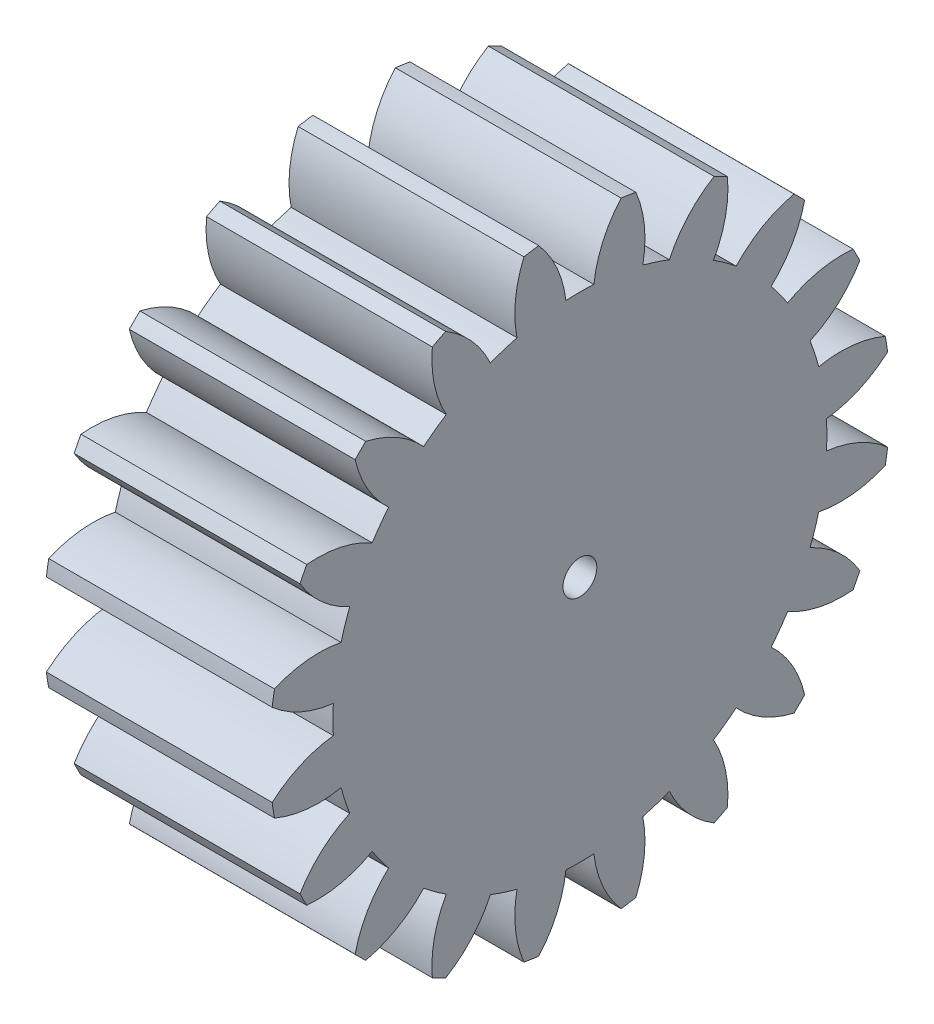
from build123d import *

# Parameters (mm, degrees)
BASPROSKE_W     = 20
BASPROSKE_H     = 27.5
TOOTHCUT_DEPTH  = 44.732139211
TEETHCUTS_COUNT = 20
TEETHCUTS_ANGLE = 342
BORSKE_R        = 1.5
BORE_DEPTH      = 50.0000508


with BuildPart() as part:
    # BasProSke → Base-Revolve (revolve)
    with BuildSketch(Plane(origin=(0, 0, 0), x_dir=(1, 0, 0), z_dir=(0, 1, 0)), mode=Mode.PRIVATE) as base_revolve_sk:
        with Locations((10, 13.75)):
            Rectangle(BASPROSKE_W, BASPROSKE_H)
    revolve(base_revolve_sk.sketch.rotate(Axis((-10, 0, 0), (1, 0, 0)), 180), axis=Axis((-10, 0, 0), (1, 0, 0)))

    # TooCutSke → ToothCut (cut, through all)
    with BuildSketch(Plane(origin=(0, 0, 0), x_dir=(0, 0, -1), z_dir=(1, 0, 0))):
        with BuildLine():
            ThreePointArc((1.237725267, 21.838954008), (0, 21.874), (-1.237725267, 21.838954008))
            ThreePointArc((-1.237725267, 21.838954008), (-2.037783758, 24.744650423), (-3.667234079, 27.280011719))
            ThreePointArc((-3.667234079, 27.280011719), (0, 27.5254), (3.667234079, 27.280011719))
            ThreePointArc((3.667234079, 27.280011719), (2.037783758, 24.744650423), (1.237725267, 21.838954008))
        make_face()
    toothcut = extrude(amount=TOOTHCUT_DEPTH, mode=Mode.SUBTRACT)

    # TeethCuts: ToothCut ×20 about axis
    teethcuts_axis = Axis((-10, 0, 0), (1, 0, 0))
    for i in range(1, TEETHCUTS_COUNT):
        add(toothcut.rotate(teethcuts_axis, i * TEETHCUTS_ANGLE / (TEETHCUTS_COUNT - 1)), mode=Mode.SUBTRACT)

    # BorSke → Bore (cut, symmetric)
    with BuildSketch(Plane(origin=(0, 0, 0), x_dir=(0, 0, -1), z_dir=(1, 0, 0))):
        with Locations(Location((0, 0, 0), (0, 0, 180))):
            Circle(BORSKE_R)
    extrude(amount=BORE_DEPTH, both=True, mode=Mode.SUBTRACT)


solid = part.part
